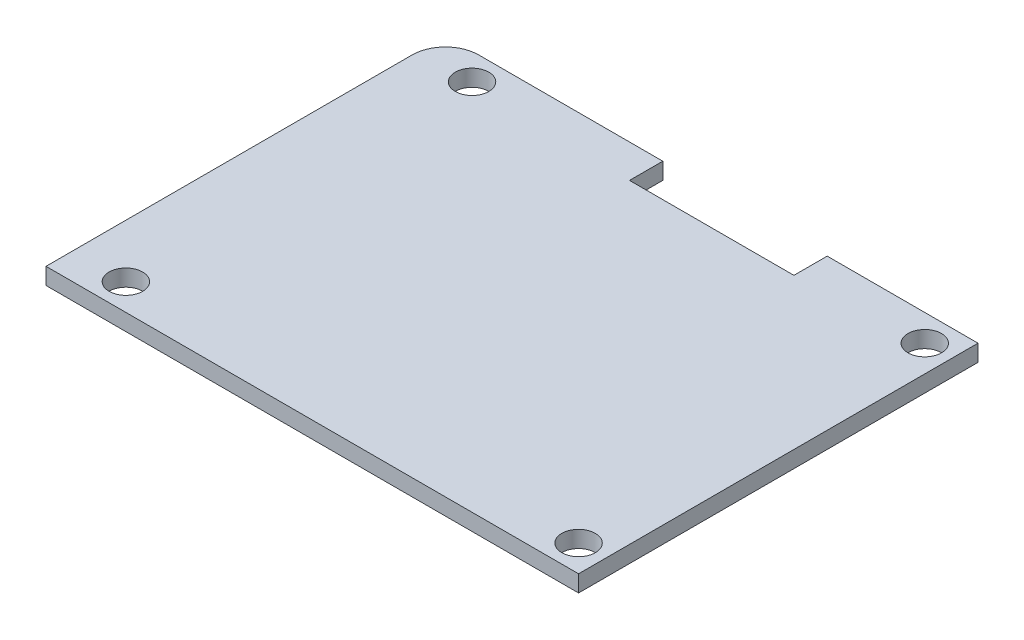
from build123d import *

# Parameters (mm, degrees)
BOSS_EXTRUDE1_DEPTH = 1.5875
SKETCH2_R           = 1.599999975
CUT_EXTRUDE1_DEPTH  = 2.5875
FILLET1_R           = 3.175


with BuildPart() as part:
    # Sketch1 → Boss-Extrude1 (new body)
    with BuildSketch(Plane(origin=(0, 0, 0), x_dir=(1, 0, 0), z_dir=(0, 1, 0))):
        Polygon((36.41598, 38.1), (50.8, 38.1), (50.8, 0), (0, 0), (0, 38.1), (20.73402, 38.1), (20.73402, 34.925), (36.41598, 34.925), align=None)
    extrude(amount=BOSS_EXTRUDE1_DEPTH)

    # Sketch2 → Cut-Extrude1 (cut, through all)
    with BuildSketch(Plane(origin=(0, 1.5875, 0), x_dir=(1, 0, 0), z_dir=(0, 1, 0))):
        with Locations(Location((5.08, 35.56, 0), (0, 0, 270))):  # turned: the seam where the file's is
            Circle(SKETCH2_R)
        with Locations(Location((48.26, 2.54, 0), (0, 0, 270))):  # turned: the seam where the file's is
            Circle(SKETCH2_R)
        with Locations(Location((48.26, 35.56, 0), (0, 0, 270))):  # turned: the seam where the file's is
            Circle(SKETCH2_R)
        with Locations(Location((5.08, 2.54, 0), (0, 0, 270))):  # turned: the seam where the file's is
            Circle(SKETCH2_R)
    extrude(amount=-CUT_EXTRUDE1_DEPTH, mode=Mode.SUBTRACT)

    # Fillet1
    fillet1_edges = [part.edges().sort_by_distance(p)[0] for p in [
        (0, 0.79375, -38.1),
    ]]
    fillet(fillet1_edges, radius=FILLET1_R)


solid = part.part
